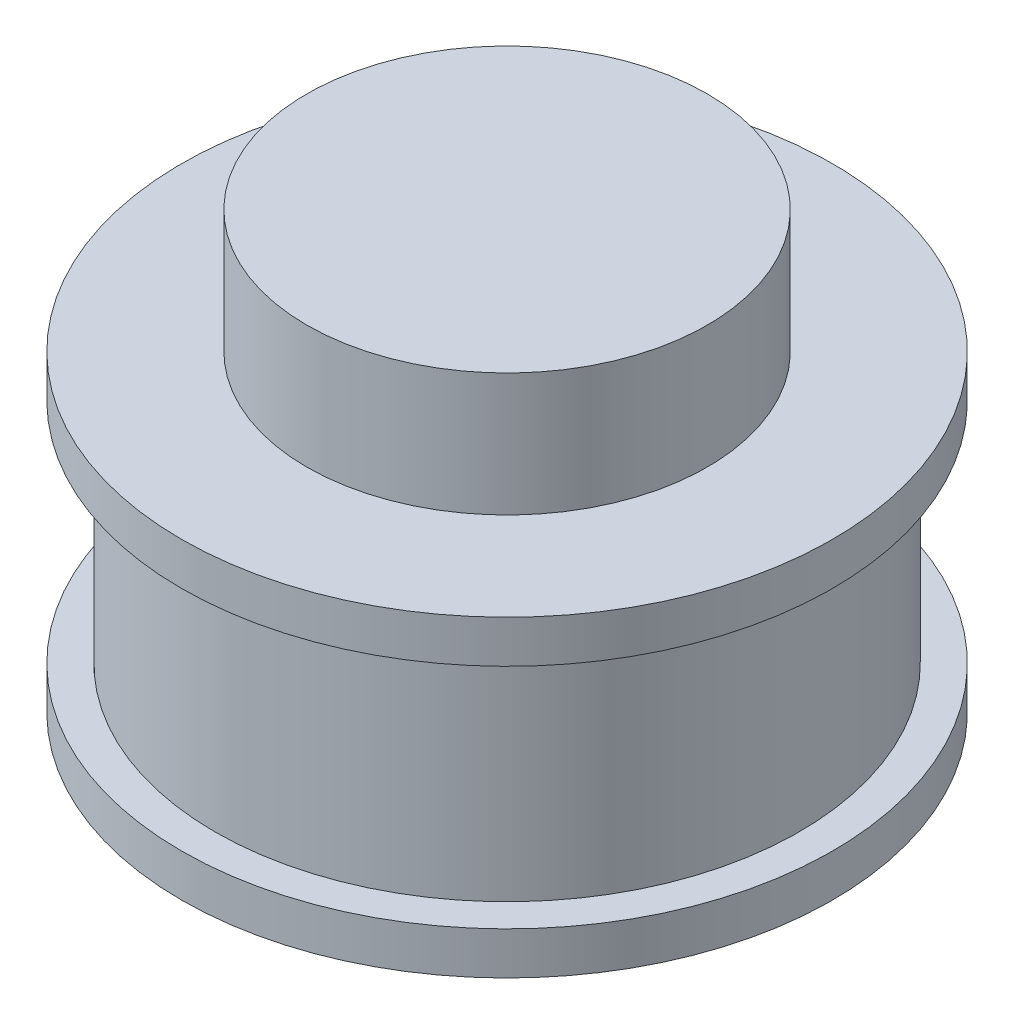
from build123d import *


with BuildPart() as part:
    # Sketch1 → Revolve1 (revolve)
    with BuildSketch(Plane.XY):
        Polygon((0, 27.6098), (12.7, 27.6098), (12.7, 19.812), (20.6375, 19.812), (20.6375, 17.114676672), (18.5293, 17.114676672), (18.5293, 2.697323328), (20.6375, 2.697323328), (20.6375, 0), (0, 0), align=None)
    revolve(axis=Axis((0, 27.6098, 0), (0, -1, 0)))


solid = part.part
